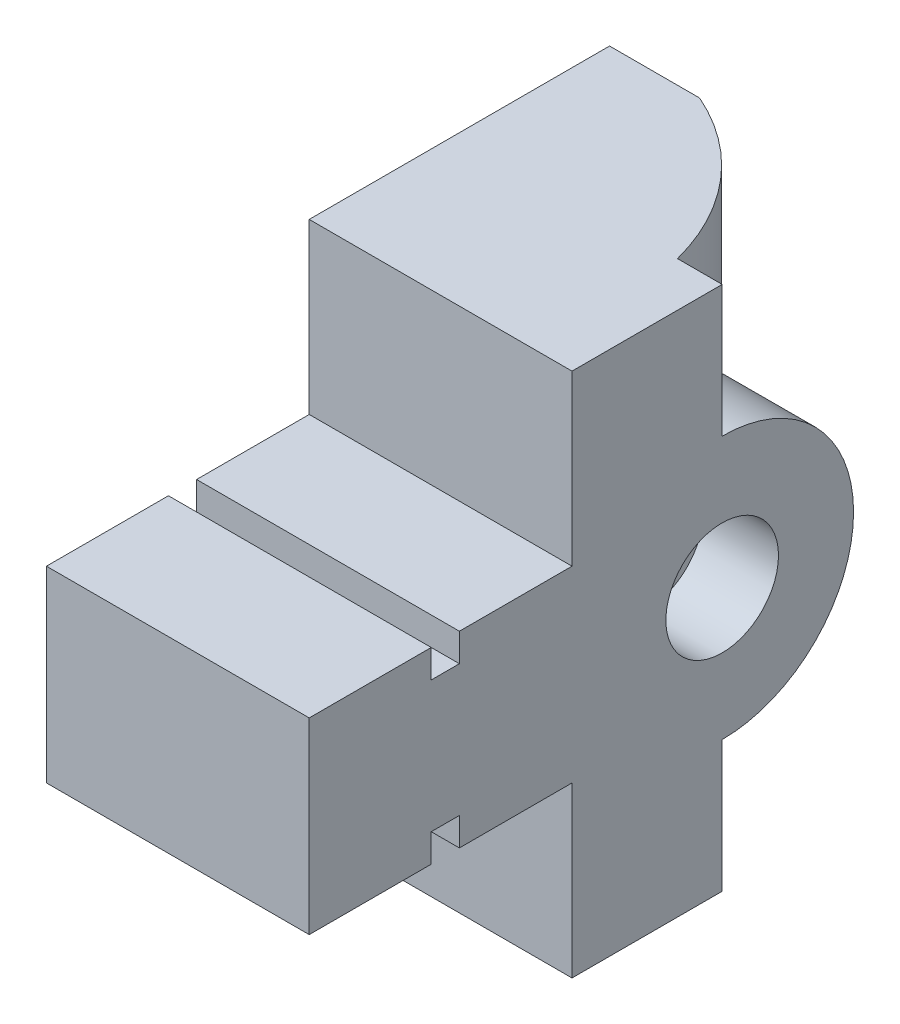
from build123d import *

# Parameters (mm, degrees)
BOSS_EXTRUDE1_DEPTH = 88.9
BOSS_EXTRUDE2_DEPTH = 44.45
CUT_EXTRUDE1_DEPTH  = 12.7
CUT_EXTRUDE2_DEPTH  = 44.45


with BuildPart() as part:
    # Sketch2 → Boss-Extrude1 (new body)
    with BuildSketch(Plane(origin=(0, 0, 0), x_dir=(1, 0, 0), z_dir=(0, 1, 0))):
        with BuildLine():
            Line((0, 0), (0, 50.8))
            Line((0, 50.8), (15.226765087, 50.8))
            ThreePointArc((15.226765087, 50.8), (28.988508692, 40.599003798), (36.890166373, 25.4))
            Line((36.890166373, 25.4), (44.45, 25.4))
            Line((44.45, 25.4), (44.45, -44.45))
            Line((44.45, -44.45), (0, -44.45))
            Line((0, -44.45), (0, 0))
        make_face()
    extrude(amount=BOSS_EXTRUDE1_DEPTH)

    # Sketch3 → Boss-Extrude2 (add)
    with BuildSketch(Plane(origin=(44.45, 0, 0), x_dir=(0, 0, -1), z_dir=(1, 0, 0))):
        with BuildLine():
            Line((25.4, 66.675), (25.4, 22.225))
            ThreePointArc((25.4, 22.225), (47.625, 44.45), (25.4, 66.675))
        make_face()
    extrude(amount=-BOSS_EXTRUDE2_DEPTH)

    # Sketch4 → Cut-Extrude1 (cut)
    with BuildSketch(Plane(origin=(44.45, 0, 0), x_dir=(0, 0, -1), z_dir=(1, 0, 0))):
        with BuildLine():
            ThreePointArc((34.925, 44.45), (32.135192091, 51.185192091), (25.4, 53.975))
            Line((25.4, 53.975), (25.4, 34.925))
            ThreePointArc((25.4, 34.925), (32.135192091, 37.714807909), (34.925, 44.45))
        make_face()
        with BuildLine():
            Line((25.4, 34.925), (25.4, 53.975))
            ThreePointArc((25.4, 53.975), (15.875, 44.45), (25.4, 34.925))
        make_face()
    extrude(amount=-CUT_EXTRUDE1_DEPTH, mode=Mode.SUBTRACT)

    # Sketch5 → Cut-Extrude2 (cut)
    with BuildSketch(Plane(origin=(44.45, 0, 0), x_dir=(0, 0, -1), z_dir=(1, 0, 0))):
        Polygon((0, 88.9), (-44.45, 88.9), (-44.45, 60.325), (-23.8125, 60.325), (-23.8125, 55.5625), (-19.05, 55.5625), (-19.05, 60.325), (0, 60.325), align=None)
        Polygon((-23.8125, 28.575), (-44.45, 28.575), (-44.45, 0), (0, 0), (0, 28.575), (-19.05, 28.575), (-19.05, 33.3375), (-23.8125, 33.3375), align=None)
    extrude(amount=-CUT_EXTRUDE2_DEPTH, mode=Mode.SUBTRACT)


solid = part.part
